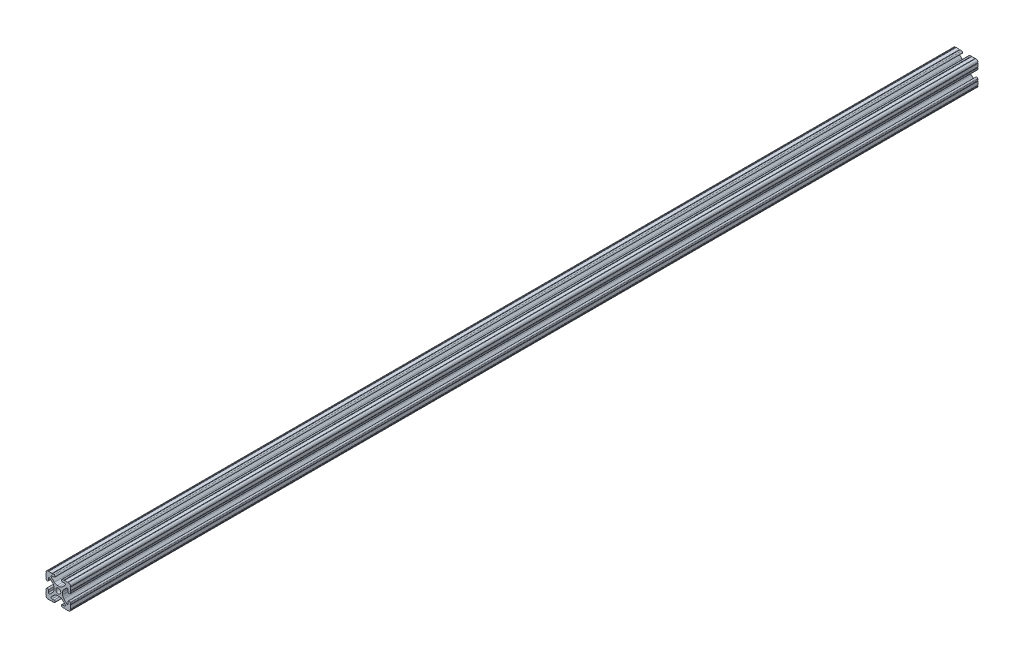
from build123d import *

# Parameters (mm, degrees)
SKETCH3_R      = 2.6035
EXTRUDE1_DEPTH = 469.9


with BuildPart() as part:
    # Sketch3 → Extrude1 (new body, symmetric)
    with BuildSketch(Plane.XY):
        with BuildLine():
            Line((-1.115277175, 4.5085), (1.115277175, 4.5085))
            ThreePointArc((1.115277175, 4.5085), (2.806584872, 4.844922018), (4.240406305, 5.80297087))
            Line((4.240406305, 5.80297087), (7.148423664, 8.710988229))
            ThreePointArc((7.148423664, 8.710988229), (7.349906316, 9.772227925), (6.436353897, 10.348636575))
            Line((6.436353897, 10.348636575), (4.381960454, 10.276895575))
            ThreePointArc((4.381960454, 10.276895575), (3.239173075, 11.342562046), (4.304839546, 12.485349424))
            Line((4.304839546, 12.485349424), (5.728246175, 12.535055879))
            ThreePointArc((5.728246175, 12.535055879), (6.054756855, 12.230579745), (6.35923299, 12.557090424))
            Line((6.35923299, 12.557090424), (9.782092278, 12.676619304))
            ThreePointArc((9.782092278, 12.676619304), (10.108602958, 12.37214317), (10.413079092, 12.69865385))
            ThreePointArc((10.413079092, 12.69865385), (12.052764565, 12.052764565), (12.69865385, 10.413079092))
            ThreePointArc((12.69865385, 10.413079092), (12.37214317, 10.108602958), (12.676619304, 9.782092278))
            Line((12.676619304, 9.782092278), (12.557090424, 6.35923299))
            ThreePointArc((12.557090424, 6.35923299), (12.230579745, 6.054756855), (12.535055879, 5.728246175))
            Line((12.535055879, 5.728246175), (12.485349424, 4.304839546))
            ThreePointArc((12.485349424, 4.304839546), (11.342562046, 3.239173075), (10.276895575, 4.381960454))
            Line((10.276895575, 4.381960454), (10.348636575, 6.436353897))
            ThreePointArc((10.348636575, 6.436353897), (9.772227925, 7.349906316), (8.710988229, 7.148423664))
            Line((8.710988229, 7.148423664), (5.80297087, 4.240406305))
            ThreePointArc((5.80297087, 4.240406305), (4.844922018, 2.806584872), (4.5085, 1.115277175))
            Line((4.5085, 1.115277175), (4.5085, -1.115277175))
            ThreePointArc((4.5085, -1.115277175), (4.844922018, -2.806584872), (5.80297087, -4.240406305))
            Line((5.80297087, -4.240406305), (8.710988229, -7.148423664))
            ThreePointArc((8.710988229, -7.148423664), (9.772227925, -7.349906316), (10.348636575, -6.436353897))
            Line((10.348636575, -6.436353897), (10.276895575, -4.381960454))
            ThreePointArc((10.276895575, -4.381960454), (11.342562046, -3.239173075), (12.485349424, -4.304839546))
            Line((12.485349424, -4.304839546), (12.535055879, -5.728246175))
            ThreePointArc((12.535055879, -5.728246175), (12.230579745, -6.054756855), (12.557090424, -6.35923299))
            Line((12.557090424, -6.35923299), (12.676619304, -9.782092278))
            ThreePointArc((12.676619304, -9.782092278), (12.37214317, -10.108602958), (12.69865385, -10.413079092))
            ThreePointArc((12.69865385, -10.413079092), (12.052764565, -12.052764565), (10.413079092, -12.69865385))
            ThreePointArc((10.413079092, -12.69865385), (10.108602958, -12.37214317), (9.782092278, -12.676619304))
            Line((9.782092278, -12.676619304), (6.35923299, -12.557090424))
            ThreePointArc((6.35923299, -12.557090424), (6.054756855, -12.230579745), (5.728246175, -12.535055879))
            Line((5.728246175, -12.535055879), (4.304839546, -12.485349424))
            ThreePointArc((4.304839546, -12.485349424), (3.239173075, -11.342562046), (4.381960454, -10.276895575))
            Line((4.381960454, -10.276895575), (6.436353897, -10.348636575))
            ThreePointArc((6.436353897, -10.348636575), (7.349906316, -9.772227925), (7.148423664, -8.710988229))
            Line((7.148423664, -8.710988229), (4.240406305, -5.80297087))
            ThreePointArc((4.240406305, -5.80297087), (2.806584872, -4.844922018), (1.115277175, -4.5085))
            Line((1.115277175, -4.5085), (-1.115277175, -4.5085))
            ThreePointArc((-1.115277175, -4.5085), (-2.806584872, -4.844922018), (-4.240406305, -5.80297087))
            Line((-4.240406305, -5.80297087), (-7.148423664, -8.710988229))
            ThreePointArc((-7.148423664, -8.710988229), (-7.349906316, -9.772227925), (-6.436353897, -10.348636575))
            Line((-6.436353897, -10.348636575), (-4.381960454, -10.276895575))
            ThreePointArc((-4.381960454, -10.276895575), (-3.239173075, -11.342562046), (-4.304839546, -12.485349424))
            Line((-4.304839546, -12.485349424), (-5.728246175, -12.535055879))
            ThreePointArc((-5.728246175, -12.535055879), (-6.054756855, -12.230579745), (-6.35923299, -12.557090424))
            Line((-6.35923299, -12.557090424), (-9.782092278, -12.676619304))
            ThreePointArc((-9.782092278, -12.676619304), (-10.108602958, -12.37214317), (-10.413079092, -12.69865385))
            ThreePointArc((-10.413079092, -12.69865385), (-12.052764565, -12.052764565), (-12.69865385, -10.413079092))
            ThreePointArc((-12.69865385, -10.413079092), (-12.37214317, -10.108602958), (-12.676619304, -9.782092278))
            Line((-12.676619304, -9.782092278), (-12.557090424, -6.35923299))
            ThreePointArc((-12.557090424, -6.35923299), (-12.230579745, -6.054756855), (-12.535055879, -5.728246175))
            Line((-12.535055879, -5.728246175), (-12.485349424, -4.304839546))
            ThreePointArc((-12.485349424, -4.304839546), (-11.342562046, -3.239173075), (-10.276895575, -4.381960454))
            Line((-10.276895575, -4.381960454), (-10.348636575, -6.436353897))
            ThreePointArc((-10.348636575, -6.436353897), (-9.772227925, -7.349906316), (-8.710988229, -7.148423664))
            Line((-8.710988229, -7.148423664), (-5.80297087, -4.240406305))
            ThreePointArc((-5.80297087, -4.240406305), (-4.844922018, -2.806584872), (-4.5085, -1.115277175))
            Line((-4.5085, -1.115277175), (-4.5085, 1.115277175))
            ThreePointArc((-4.5085, 1.115277175), (-4.844922018, 2.806584872), (-5.80297087, 4.240406305))
            Line((-5.80297087, 4.240406305), (-8.710988229, 7.148423664))
            ThreePointArc((-8.710988229, 7.148423664), (-9.772227925, 7.349906316), (-10.348636575, 6.436353897))
            Line((-10.348636575, 6.436353897), (-10.276895575, 4.381960454))
            ThreePointArc((-10.276895575, 4.381960454), (-11.342562046, 3.239173075), (-12.485349424, 4.304839546))
            Line((-12.485349424, 4.304839546), (-12.535055879, 5.728246175))
            ThreePointArc((-12.535055879, 5.728246175), (-12.230579745, 6.054756855), (-12.557090424, 6.35923299))
            Line((-12.557090424, 6.35923299), (-12.676619304, 9.782092278))
            ThreePointArc((-12.676619304, 9.782092278), (-12.37214317, 10.108602958), (-12.69865385, 10.413079092))
            ThreePointArc((-12.69865385, 10.413079092), (-12.052764565, 12.052764565), (-10.413079092, 12.69865385))
            ThreePointArc((-10.413079092, 12.69865385), (-10.108602958, 12.37214317), (-9.782092278, 12.676619304))
            Line((-9.782092278, 12.676619304), (-6.35923299, 12.557090424))
            ThreePointArc((-6.35923299, 12.557090424), (-6.054756855, 12.230579745), (-5.728246175, 12.535055879))
            Line((-5.728246175, 12.535055879), (-4.304839546, 12.485349424))
            ThreePointArc((-4.304839546, 12.485349424), (-3.239173075, 11.342562046), (-4.381960454, 10.276895575))
            Line((-4.381960454, 10.276895575), (-6.436353897, 10.348636575))
            ThreePointArc((-6.436353897, 10.348636575), (-7.349906316, 9.772227925), (-7.148423664, 8.710988229))
            Line((-7.148423664, 8.710988229), (-4.240406305, 5.80297087))
            ThreePointArc((-4.240406305, 5.80297087), (-2.806584872, 4.844922018), (-1.115277175, 4.5085))
        make_face()
        Circle(SKETCH3_R, mode=Mode.SUBTRACT)
    extrude(amount=EXTRUDE1_DEPTH, both=True)


solid = part.part
